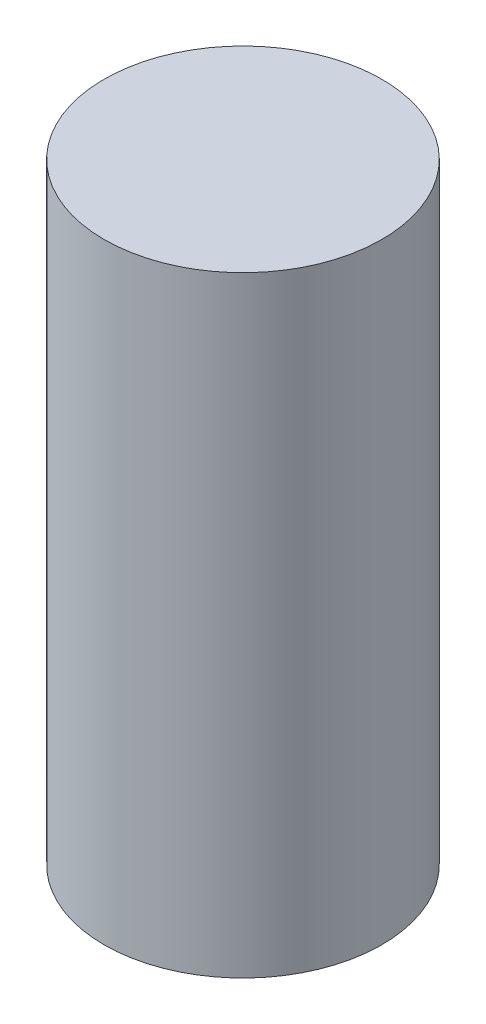
from build123d import *

# Parameters (mm, degrees)
SKETCH1_R           = 25
BOSS_EXTRUDE1_DEPTH = 110


with BuildPart() as part:
    # Sketch1 → Boss-Extrude1 (new body)
    with BuildSketch(Plane(origin=(0, 0, 0), x_dir=(1, 0, 0), z_dir=(0, 1, 0))):
        Circle(SKETCH1_R)
    extrude(amount=BOSS_EXTRUDE1_DEPTH)


solid = part.part
